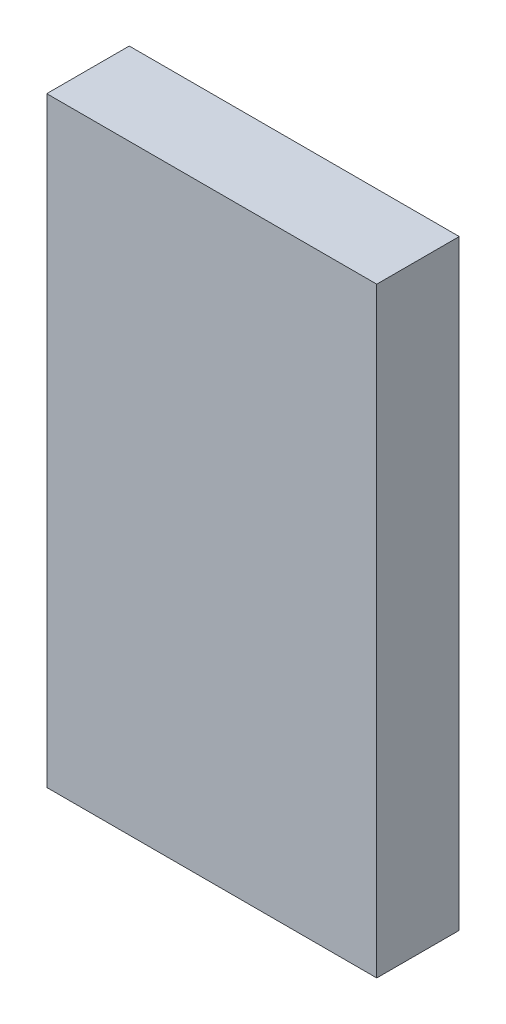
from build123d import *

# Parameters (mm, degrees)
SKICA1_W                = 10.16
SKICA1_H                = 2.54
P_IDAT_VYSUNUT_M1_DEPTH = 18.5


with BuildPart() as part:
    # Skica1 → Přidat vysunutím1 (new body)
    with BuildSketch(Plane(origin=(0, 0, 0), x_dir=(1, 0, 0), z_dir=(0, 1, 0))):
        Rectangle(SKICA1_W, SKICA1_H)
    extrude(amount=P_IDAT_VYSUNUT_M1_DEPTH)


solid = part.part
